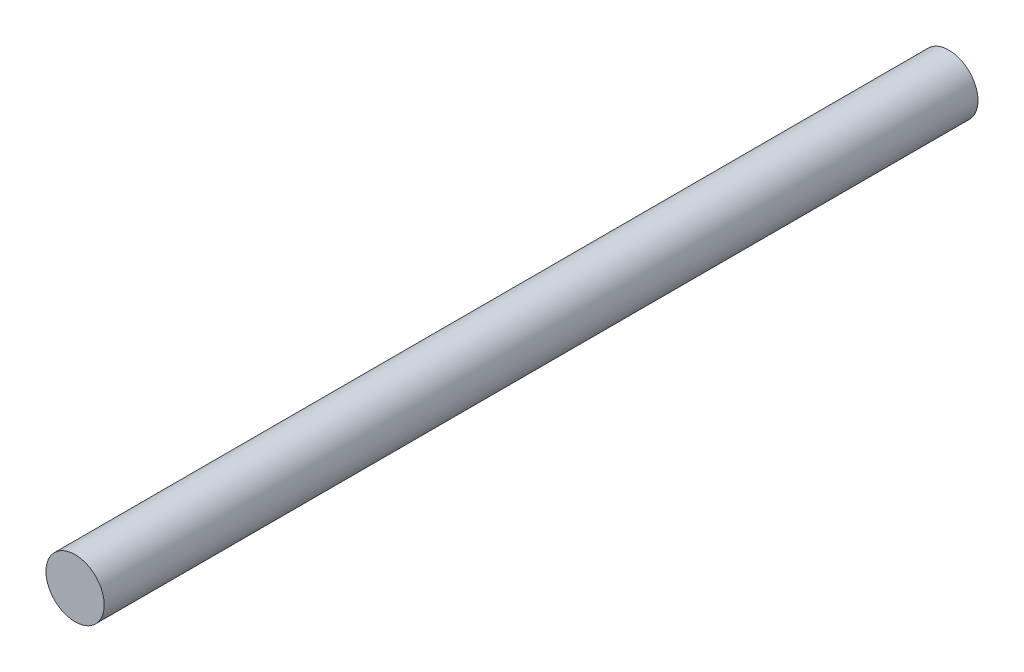
from build123d import *

# Parameters (mm, degrees)
SKETCH1_R           = 1
BOSS_EXTRUDE1_DEPTH = 30


with BuildPart() as part:
    # Sketch1 → Boss-Extrude1 (new body)
    with BuildSketch(Plane.XY):
        with Locations((0, 10.610944307)):
            Circle(SKETCH1_R)
    extrude(amount=BOSS_EXTRUDE1_DEPTH)


solid = part.part
